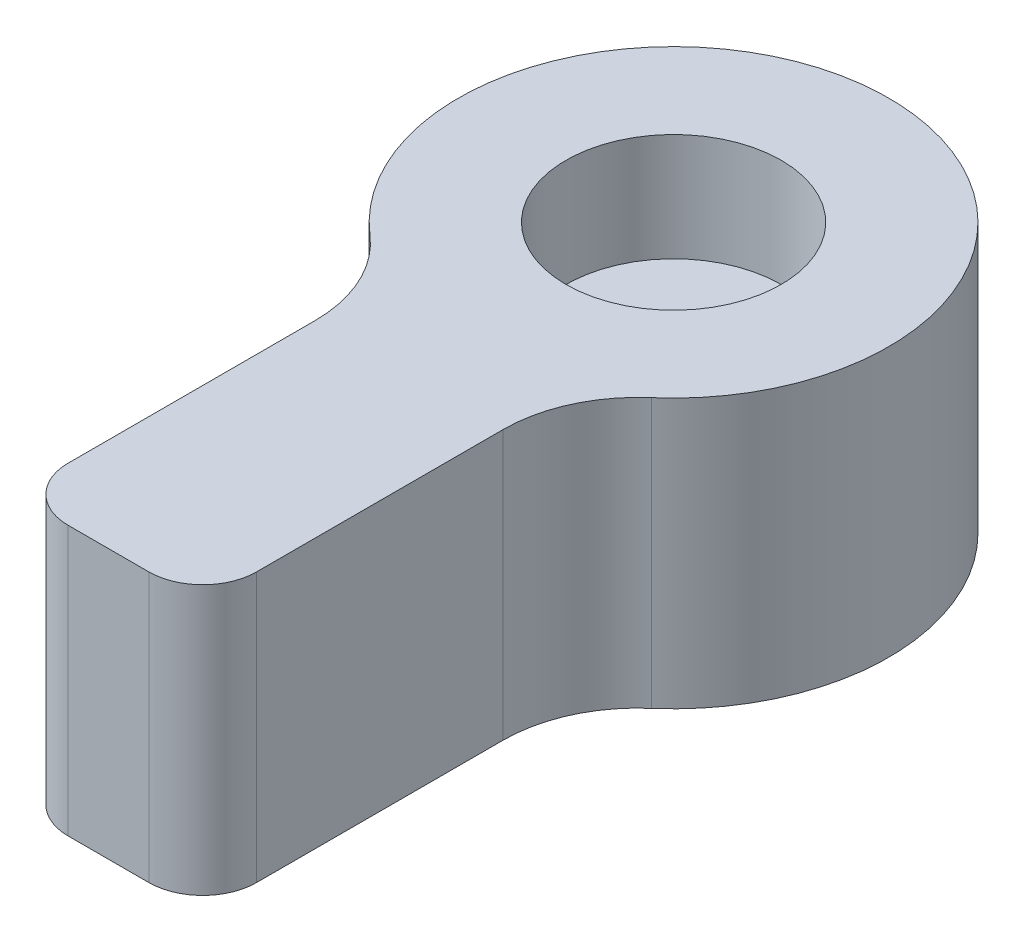
from build123d import *

# Parameters (mm, degrees)
EXTRUDE_1_DEPTH     = 10
FILLET_1_R          = 2
FILLET_2_R          = 5
SKETCH_4_R          = 4
CUT_EXTRUDE_1_DEPTH = 4
M4X0_71_D           = 3.3


with BuildPart() as part:
    # Эскиз1 → Бобышка-Вытянуть1 (new body)
    with BuildSketch(Plane(origin=(0, 0, 0), x_dir=(1, 0, 0), z_dir=(0, 1, 0))):
        with BuildLine():
            Line((-3.5, -7.193747285), (-3.5, -21))
            Line((-3.5, -21), (3.5, -21))
            Line((3.5, -21), (3.5, -7.193747285))
            ThreePointArc((3.5, -7.193747285), (0, 8), (-3.5, -7.193747285))
        make_face()
    extrude(amount=EXTRUDE_1_DEPTH)

    # Скругление1
    fillet_1_edges = [part.edges().sort_by_distance(p)[0] for p in [
        (3.5, 5, 21),
        (-3.5, 5, 21),
    ]]
    fillet(fillet_1_edges, radius=FILLET_1_R)

    # Скругление2
    fillet_2_edges = [part.edges().sort_by_distance(p)[0] for p in [
        (-3.5, 5, 7.193747285),
        (3.5, 5, 7.193747285),
    ]]
    fillet(fillet_2_edges, radius=FILLET_2_R)

    # Эскиз4 → Вырез-Вытянуть1 (cut)
    with BuildSketch(Plane(origin=(0, 10, 0), x_dir=(1, 0, 0), z_dir=(0, 1, 0))):
        Circle(SKETCH_4_R)
    extrude(amount=-CUT_EXTRUDE_1_DEPTH, mode=Mode.SUBTRACT)

    # Отверстие обработанное метчиком M4x0.71 (through all)
    with Locations(Plane(origin=(0, 6, 0), x_dir=(1, 0, 0), z_dir=(0, 1, 0))):
        with Locations((0, 0)):
            Hole(M4X0_71_D / 2)


solid = part.part
